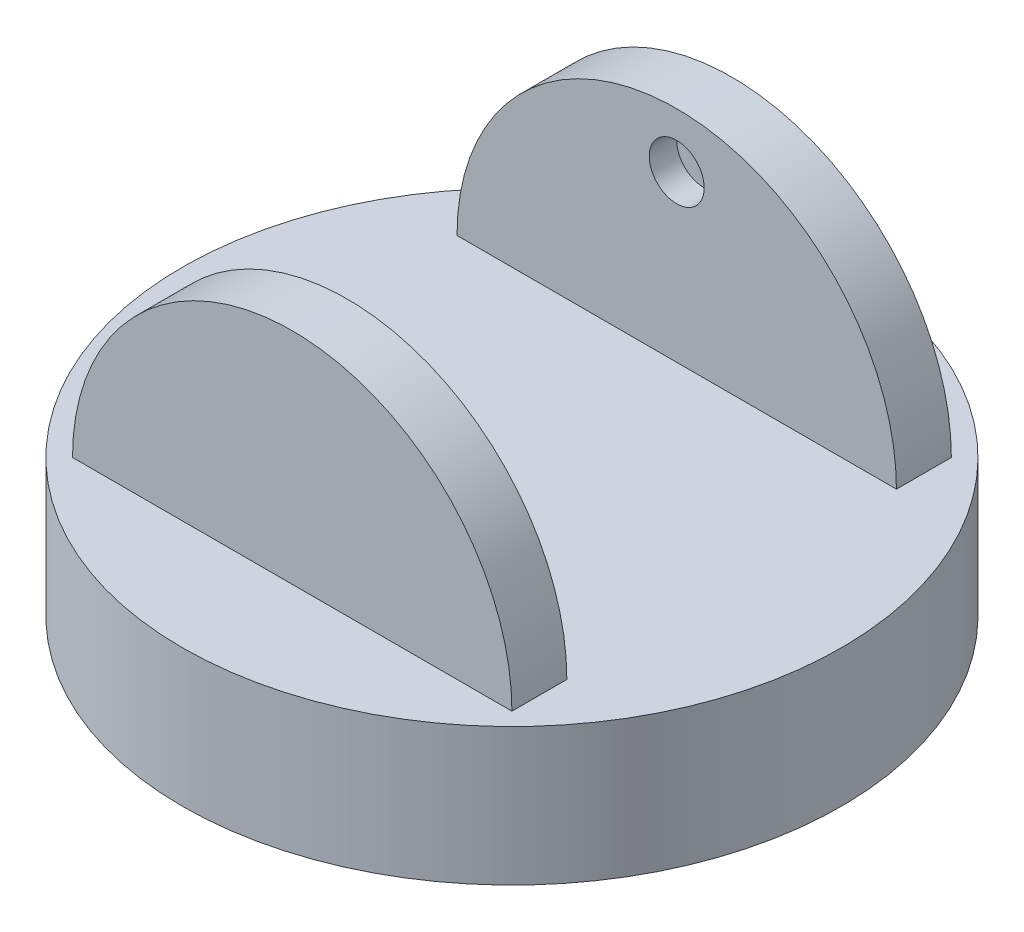
from build123d import *

# Parameters (mm, degrees)
SKETCH1_R           = 60
BOSS_EXTRUDE1_DEPTH = 25
BOSS_EXTRUDE2_DEPTH = 40
SKETCH3_W           = 80
SKETCH3_H           = 60
CUT_EXTRUDE1_DEPTH  = 60
SKETCH4_R           = 5
CUT_EXTRUDE2_DEPTH  = 5


with BuildPart() as part:
    # Sketch1 → Boss-Extrude1 (new body)
    with BuildSketch(Plane(origin=(0, 0, 0), x_dir=(1, 0, 0), z_dir=(0, 1, 0))):
        Circle(SKETCH1_R)
    extrude(amount=BOSS_EXTRUDE1_DEPTH)

    # Sketch2 → Boss-Extrude2 (add)
    with BuildSketch(Plane.XY):
        with BuildLine():
            Line((-40, 25), (0, 25))
            Line((0, 25), (40, 25))
            ThreePointArc((40, 25), (0, 65), (-40, 25))
        make_face()
    boss_extrude2 = extrude(amount=BOSS_EXTRUDE2_DEPTH)

    # Mirror1: Boss-Extrude2 across plane
    add(boss_extrude2.mirror(Plane(origin=(0, 0, 0), x_dir=(1, 0, 0), z_dir=(0, 0, -1))))

    # Sketch3 → Cut-Extrude1 (cut)
    with BuildSketch(Plane(origin=(0, 25, 0), x_dir=(1, 0, 0), z_dir=(0, 1, 0))):
        Rectangle(SKETCH3_W, SKETCH3_H)
    extrude(amount=CUT_EXTRUDE1_DEPTH, mode=Mode.SUBTRACT)

    # Sketch4 → Cut-Extrude2 (cut)
    with BuildSketch(Plane.XY.offset(-30)):
        with Locations((0, 55)):
            Circle(SKETCH4_R)
    cut_extrude2 = extrude(amount=-CUT_EXTRUDE2_DEPTH, mode=Mode.SUBTRACT)

    # Mirror2: Cut-Extrude2 across plane
    add(cut_extrude2.mirror(Plane(origin=(0, 0, 0), x_dir=(1, 0, 0), z_dir=(0, 0, -1))), mode=Mode.SUBTRACT)


solid = part.part
